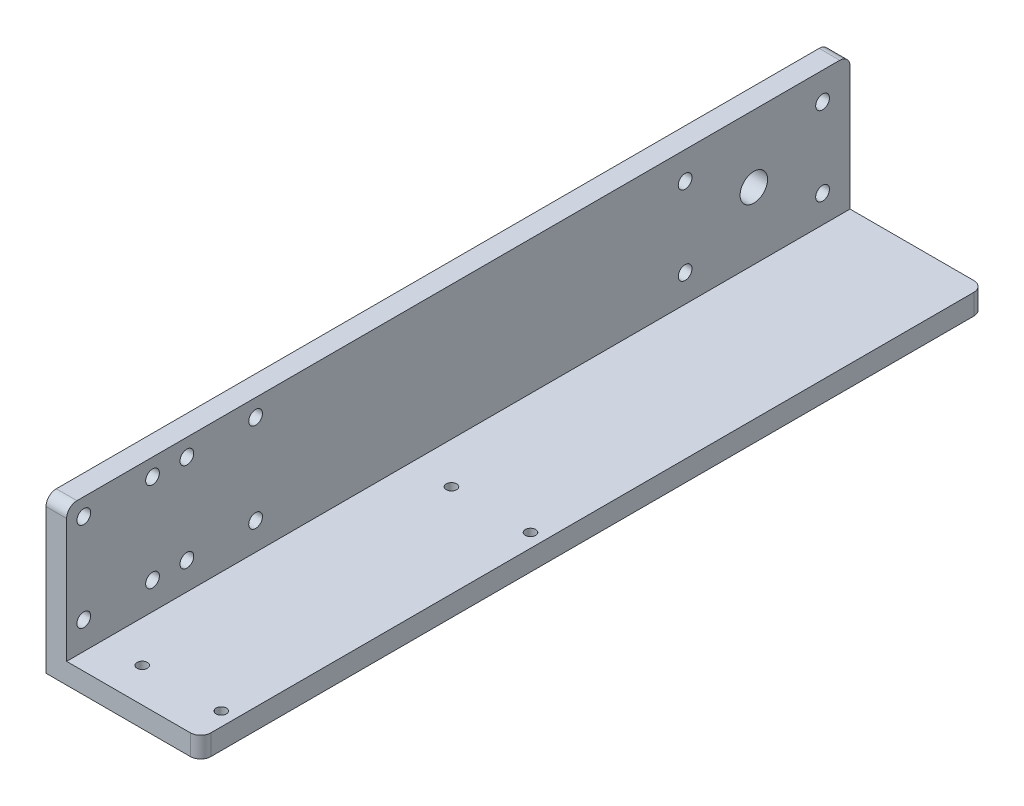
from build123d import *

# Parameters (mm, degrees)
BOSS_EXTRUDE1_DEPTH = 228
FILLET1_R           = 3
SKETCH5_R           = 2
CUT_EXTRUDE2_DEPTH  = 46
SKETCH6_R           = 2
CUT_EXTRUDE3_DEPTH  = 46
SKETCH7_R           = 4
CUT_EXTRUDE4_DEPTH  = 46
SKETCH8_R           = 1.5
CUT_EXTRUDE5_DEPTH  = 7


with BuildPart() as part:
    # Sketch2 → Boss-Extrude1 (new body)
    with BuildSketch(Plane.XY):
        Polygon((82.969208633, 26.8), (82.969208633, -12.2), (121.969208633, -12.2), (121.969208633, -18.2), (82.969208633, -18.2), (76.969208633, -18.2), (76.969208633, -12.2), (76.969208633, 26.8), align=None)
    extrude(amount=BOSS_EXTRUDE1_DEPTH)

    # Fillet1
    fillet1_edges = [part.edges().sort_by_distance(p)[0] for p in [
        (79.969208633, 26.8, 0),
        (121.969208633, -15.2, 228),
        (79.969208633, 26.8, 228),
        (121.969208633, -15.2, 0),
    ]]
    fillet(fillet1_edges, radius=FILLET1_R)

    # Sketch5 → Cut-Extrude2 (cut, through all)
    with BuildSketch(Plane.ZY.offset(-76.969208633)):
        with Locations((223, 21.8)):
            Circle(SKETCH5_R)
        with Locations((223, -4.2)):
            Circle(SKETCH5_R)
        with Locations((203, 21.8)):
            Circle(SKETCH5_R)
        with Locations((203, -4.2)):
            Circle(SKETCH5_R)
    cut_extrude2 = extrude(amount=-CUT_EXTRUDE2_DEPTH, mode=Mode.SUBTRACT)

    # Mirror1: Cut-Extrude2 across plane
    add(cut_extrude2.mirror(Plane.XY.offset(198)), mode=Mode.SUBTRACT)

    # Sketch6 → Cut-Extrude3 (cut, through all)
    with BuildSketch(Plane.ZY.offset(-76.969208633)):
        with Locations((8, 18.8)):
            Circle(SKETCH6_R)
        with Locations((48, 18.8)):
            Circle(SKETCH6_R)
        with Locations((8, -4.2)):
            Circle(SKETCH6_R)
        with Locations((48, -4.2)):
            Circle(SKETCH6_R)
    extrude(amount=-CUT_EXTRUDE3_DEPTH, mode=Mode.SUBTRACT)

    # Sketch7 → Cut-Extrude4 (cut, through all)
    with BuildSketch(Plane.ZY.offset(-76.969208633)):
        with Locations((28, 7.3)):
            Circle(SKETCH7_R)
    extrude(amount=-CUT_EXTRUDE4_DEPTH, mode=Mode.SUBTRACT)

    # Sketch8 → Cut-Extrude5 (cut, through all)
    with BuildSketch(Plane(origin=(0, -12.2, 0), x_dir=(1, 0, 0), z_dir=(0, 1, 0))):
        with Locations((94.969208633, -218)):
            Circle(SKETCH8_R)
        with Locations((117.969208633, -218)):
            Circle(SKETCH8_R)
        with Locations((117.969208633, -128)):
            Circle(SKETCH8_R)
        with Locations((94.969208633, -128)):
            Circle(SKETCH8_R)
    extrude(amount=-CUT_EXTRUDE5_DEPTH, mode=Mode.SUBTRACT)


solid = part.part
